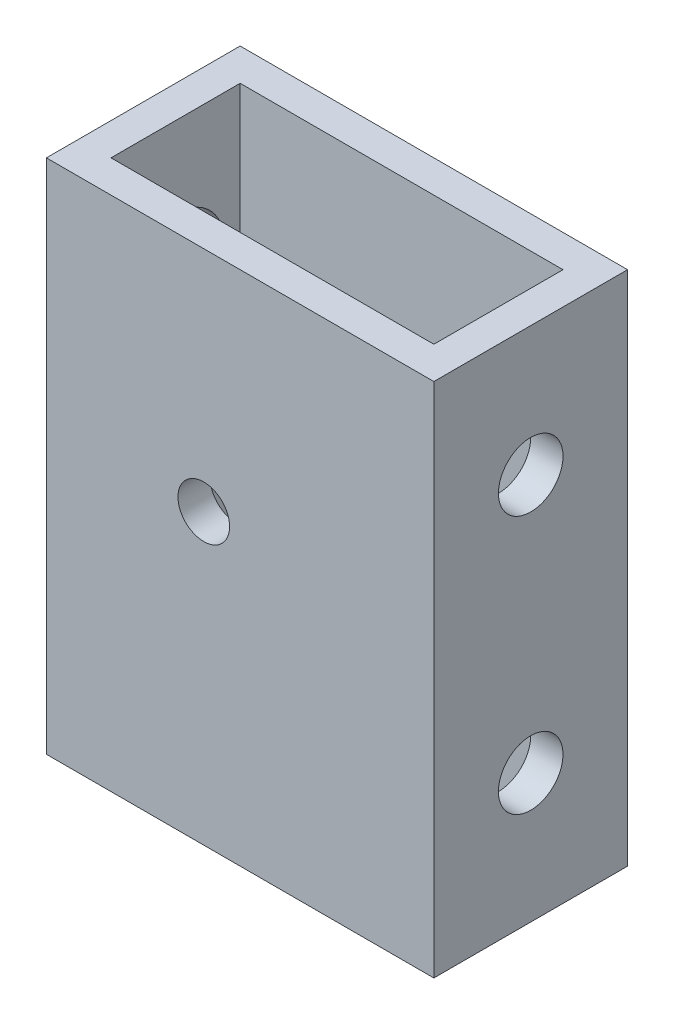
from build123d import *

# Parameters (mm, degrees)
SKETCH1_W           = 38.1
SKETCH1_H           = 19.05
SKETCH1_W_2         = 31.75
SKETCH1_H_2         = 12.7
BOSS_EXTRUDE1_DEPTH = 50.8
SKETCH2_R           = 3.175
CUT_EXTRUDE1_DEPTH  = 39.1
SKETCH3_R           = 2.54
CUT_EXTRUDE2_DEPTH  = 20.05
CUT_EXTRUDE3_REACH  = 40.1
SKETCH4_R           = 4.7625


with BuildPart() as part:
    # Sketch1 → Boss-Extrude1 (new body)
    with BuildSketch(Plane(origin=(0, 0, 0), x_dir=(1, 0, 0), z_dir=(0, 1, 0))):
        with Locations((19.05, 9.525)):
            Rectangle(SKETCH1_W, SKETCH1_H)
        with Locations((19.05, 9.525)):
            Rectangle(SKETCH1_W_2, SKETCH1_H_2, mode=Mode.SUBTRACT)
    extrude(amount=BOSS_EXTRUDE1_DEPTH)

    # Sketch2 → Cut-Extrude1 (cut, through all)
    with BuildSketch(Plane(origin=(38.1, 0, 0), x_dir=(0, 0, -1), z_dir=(1, 0, 0))):
        with Locations((9.525, 38.1)):
            Circle(SKETCH2_R)
        with Locations((9.525, 12.7)):
            Circle(SKETCH2_R)
    extrude(amount=-CUT_EXTRUDE1_DEPTH, mode=Mode.SUBTRACT)

    # Sketch3 → Cut-Extrude2 (cut, through all)
    with BuildSketch(Plane.XY):
        with Locations((15.473378078, 28.395613607)):
            Circle(SKETCH3_R)
    extrude(amount=-CUT_EXTRUDE2_DEPTH, mode=Mode.SUBTRACT)

    # Sketch4 → Cut-Extrude3 (cut, up to next)
    with BuildSketch(Plane.ZY, mode=Mode.PRIVATE) as cut_extrude3_sk1:
        with Locations((-9.525, 12.7)):
            Circle(SKETCH4_R)
    cut_extrude3_tool1 = extrude(cut_extrude3_sk1.sketch, amount=-CUT_EXTRUDE3_REACH, mode=Mode.PRIVATE) & part.part
    add(cut_extrude3_tool1.solids().sort_by_distance((0, 12.7, -9.525))[0], mode=Mode.SUBTRACT)
    # Sketch4 → Cut-Extrude3 (cut, up to next)
    with BuildSketch(Plane.ZY, mode=Mode.PRIVATE) as cut_extrude3_sk2:
        with Locations((-9.525, 38.1)):
            Circle(SKETCH4_R)
    cut_extrude3_tool2 = extrude(cut_extrude3_sk2.sketch, amount=-CUT_EXTRUDE3_REACH, mode=Mode.PRIVATE) & part.part
    add(cut_extrude3_tool2.solids().sort_by_distance((0, 38.1, -9.525))[0], mode=Mode.SUBTRACT)


solid = part.part
